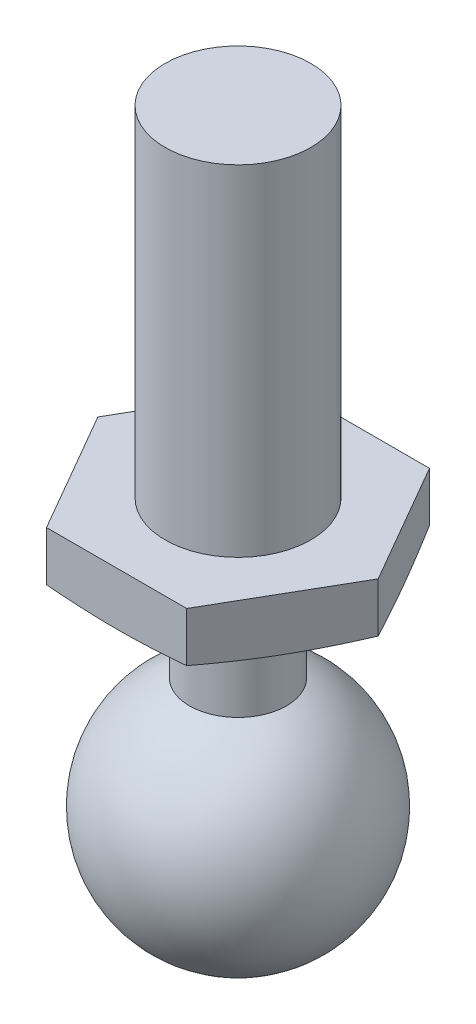
from build123d import *

# Parameters (mm, degrees)
SKETCH2_OUTSIDE_W  = 11.446
SKETCH2_OUTSIDE_H  = 11.446
CUT_EXTRUDE1_DEPTH = 2


with BuildPart() as part:
    # Sketch1 → Revolve1 (revolve)
    with BuildSketch(Plane(origin=(0, 0, 0), x_dir=(0, 0, -1), z_dir=(1, 0, 0))):
        with BuildLine():
            Line((0, 7), (1.5, 7))
            Line((1.5, 7), (1.5, 0))
            Line((1.5, 0), (3, 0))
            Line((3, 0), (3, -1))
            Line((3, -1), (1, -1.352653961))
            Line((1, -1.352653961), (1, -3.208712153))
            ThreePointArc((1, -3.208712153), (2.447265782, -6.010774109), (0, -8))
            Line((0, -8), (0, 7))
        make_face()
    revolve(axis=Axis((0, -8, 0), (0, 1, 0)))

    # Sketch2 outside → Cut-Extrude1 (cut)
    with BuildSketch(Plane(origin=(0, 0, 0), x_dir=(1, 0, 0), z_dir=(0, 1, 0))):
        Rectangle(SKETCH2_OUTSIDE_W, SKETCH2_OUTSIDE_H)
        Polygon((1.443375673, 2.5), (-1.443375673, 2.5), (-2.886751346, 0), (-1.443375673, -2.5), (1.443375673, -2.5), (2.886751346, 0), align=None, mode=Mode.SUBTRACT)
    extrude(amount=-CUT_EXTRUDE1_DEPTH, mode=Mode.SUBTRACT)


solid = part.part
